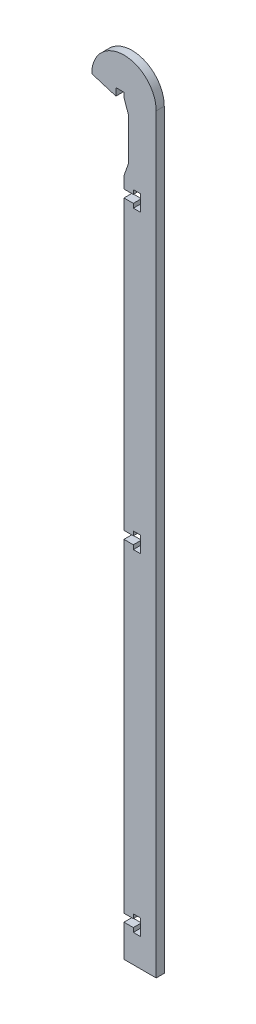
from build123d import *

# Parameters (mm, degrees)
BOSS_EXTRUDE1_DEPTH = 3.175


with BuildPart() as part:
    # Sketch1 → Boss-Extrude1 (new body)
    with BuildSketch(Plane.XY):
        with BuildLine():
            Line((0, 0), (0, -1.8034))
            Line((0, -1.8034), (1.778, -6.8834))
            Line((1.778, -6.8834), (1.778, -23.3934))
            Line((1.778, -23.3934), (0, -28.4734))
            Line((0, -28.4734), (0, -33.02))
            Line((0, -33.02), (3.683, -33.02))
            Line((3.683, -33.02), (3.683, -31.369))
            Line((3.683, -31.369), (6.477, -31.369))
            Line((6.477, -31.369), (6.477, -37.719))
            Line((6.477, -37.719), (3.683, -37.719))
            Line((3.683, -37.719), (3.683, -36.068))
            Line((3.683, -36.068), (0, -36.068))
            Line((0, -36.068), (0, -149.521333333))
            Line((0, -149.521333333), (3.683, -149.521333333))
            Line((3.683, -149.521333333), (3.683, -147.870333333))
            Line((3.683, -147.870333333), (6.477, -147.870333333))
            Line((6.477, -147.870333333), (6.477, -154.220333333))
            Line((6.477, -154.220333333), (3.683, -154.220333333))
            Line((3.683, -154.220333333), (3.683, -152.569333333))
            Line((3.683, -152.569333333), (0, -152.569333333))
            Line((0, -152.569333333), (0, -280.162))
            Line((0, -280.162), (3.683, -280.162))
            Line((3.683, -280.162), (3.683, -278.511))
            Line((3.683, -278.511), (6.477, -278.511))
            Line((6.477, -278.511), (6.477, -284.861))
            Line((6.477, -284.861), (3.683, -284.861))
            Line((3.683, -284.861), (3.683, -283.21))
            Line((3.683, -283.21), (0, -283.21))
            Line((0, -283.21), (0, -295.91))
            Line((0, -295.91), (12.7, -295.91))
            Line((12.7, -295.91), (12.7, 0))
            ThreePointArc((12.7, 0), (0, 12.7), (-12.7, 0))
            Line((-12.7, 0), (-3.175, -2.921))
            Line((-3.175, -2.921), (-3.175, 0))
            Line((-3.175, 0), (0, 0))
        make_face()
    extrude(amount=BOSS_EXTRUDE1_DEPTH)


solid = part.part
